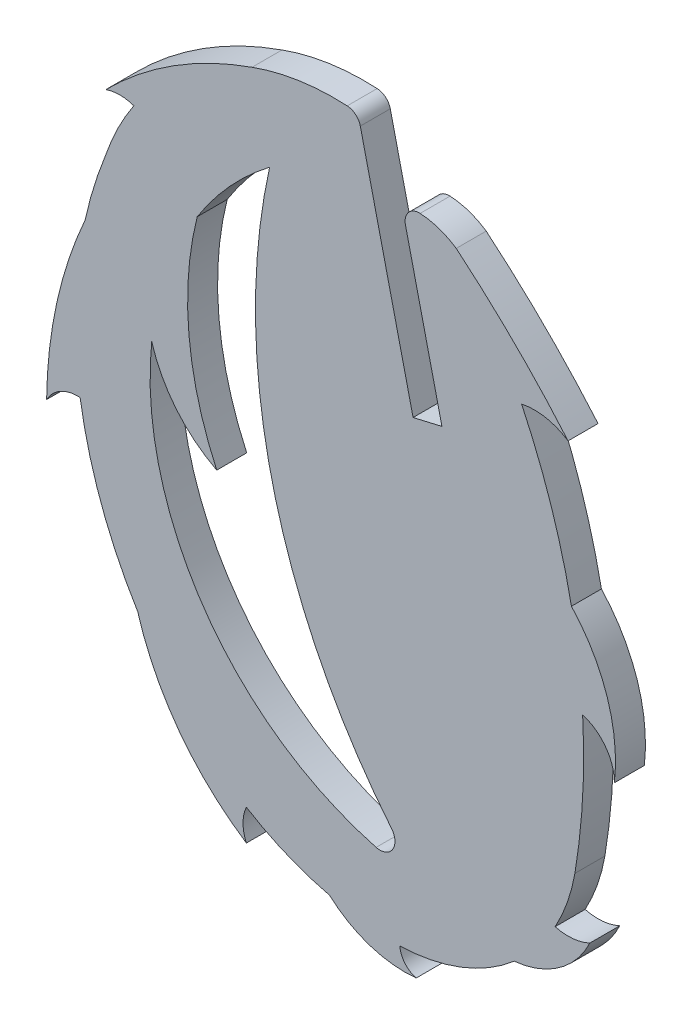
from build123d import *

# Parameters (mm, degrees)
BOSS_EXTRUDE1_DEPTH = 1.524


with BuildPart() as part:
    # Sketch1 → Boss-Extrude1 (new body)
    with BuildSketch(Plane.XY):
        with BuildLine():
            Line((4.256917141, 5.769411883), (1.572809007, 17.263448795))
            ThreePointArc((1.572809007, 17.263448795), (1.33277356, 17.653503195), (0.906545614, 17.821101488))
            ThreePointArc((0.906545614, 17.821101488), (-1.551180683, 17.70350979), (-3.936309018, 17.099018945))
            ThreePointArc((-3.936309018, 17.099018945), (-7.921935156, 15.173641861), (-11.370512849, 12.398825736))
            ThreePointArc((-11.370512849, 12.398825736), (-10.65795085, 12.520948262), (-9.945388851, 12.398825736))
            ThreePointArc((-9.945388851, 12.398825736), (-10.75175796, 11.010980832), (-11.370512849, 9.529938291))
            ThreePointArc((-11.370512849, 9.529938291), (-11.970031651, 7.843351342), (-12.427355406, 6.112786892))
            ThreePointArc((-12.427355406, 6.112786892), (-13.861120773, 1.778008598), (-14.380967646, -2.758040919))
            ThreePointArc((-14.380967646, -2.758040919), (-13.666638109, -2.037962277), (-12.676602307, -1.817487676))
            ThreePointArc((-12.676602307, -1.817487676), (-11.608509665, -5.94620724), (-9.747451479, -9.783342834))
            ThreePointArc((-9.747451479, -9.783342834), (-7.642342319, -13.987011856), (-4.222302714, -17.212790355))
            ThreePointArc((-4.222302714, -17.212790355), (-4.393060991, -16.422566374), (-4.222302714, -15.632342393))
            ThreePointArc((-4.222302714, -15.632342393), (-2.181732974, -16.682038059), (0, -17.393253279))
            ThreePointArc((0, -17.393253279), (2.054844162, -18.583773873), (4.416134447, -18.836819344))
            ThreePointArc((4.416134447, -18.836819344), (3.835913361, -18.472367282), (3.582858973, -17.835621422))
            ThreePointArc((3.582858973, -17.835621422), (6.685181318, -17.225290735), (9.400931472, -15.606152513))
            ThreePointArc((9.400931472, -15.606152513), (11.681500609, -14.751428539), (13.244817958, -12.883920166))
            ThreePointArc((13.244817958, -12.883920166), (12.377103481, -13.119413472), (11.481010343, -13.045911095))
            ThreePointArc((11.481010343, -13.045911095), (12.101156665, -11.660968144), (12.48661751, -10.193293666))
            ThreePointArc((12.48661751, -10.193293666), (12.882572593, -6.614027713), (12.879735524, -3.012928279))
            ThreePointArc((12.879735524, -3.012928279), (14.048115247, -3.839488411), (14.493985036, -5.19945641))
            ThreePointArc((14.493985036, -5.19945641), (14.133433894, -1.619098645), (12.309709537, 1.482995539))
            ThreePointArc((12.309709537, 1.482995539), (11.280344817, 5.382263311), (9.775547345, 9.123849265))
            ThreePointArc((9.775547345, 9.123849265), (11.001373452, 9.138607919), (12.138839862, 8.681401588))
            ThreePointArc((12.138839862, 8.681401588), (9.414557137, 11.619631747), (6.450200817, 14.315462683))
            ThreePointArc((6.450200817, 14.315462683), (5.574364255, 14.751975507), (4.613492818, 14.937337889))
            ThreePointArc((4.613492818, 14.937337889), (4.020029106, 14.680075469), (3.869846118, 14.050926679))
            Line((3.869846118, 14.050926679), (5.723654442, 6.111784154))
            Line((5.723654442, 6.111784154), (4.256917141, 5.769411883))
        make_face()
        with BuildLine():
            ThreePointArc((-3.040310387, 13.14603457), (-5.059685303, 11.298393601), (-6.72191547, 9.123849265))
            ThreePointArc((-6.72191547, 9.123849265), (-7.142476483, 3.70580008), (-5.728856427, -1.541466531))
            ThreePointArc((-5.728856427, -1.541466531), (-7.793494607, 0.12430808), (-9.03431247, 2.469069667))
            ThreePointArc((-9.03431247, 2.469069667), (-6.389960205, -7.924495098), (2.376676031, -14.102267879))
            ThreePointArc((2.376676031, -14.102267879), (3.21284, -13.778999141), (3.16277516, -12.883920166))
            ThreePointArc((3.16277516, -12.883920166), (-2.923149595, -0.580137917), (-3.040310387, 13.14603457))
        make_face(mode=Mode.SUBTRACT)
    extrude(amount=BOSS_EXTRUDE1_DEPTH)


solid = part.part
